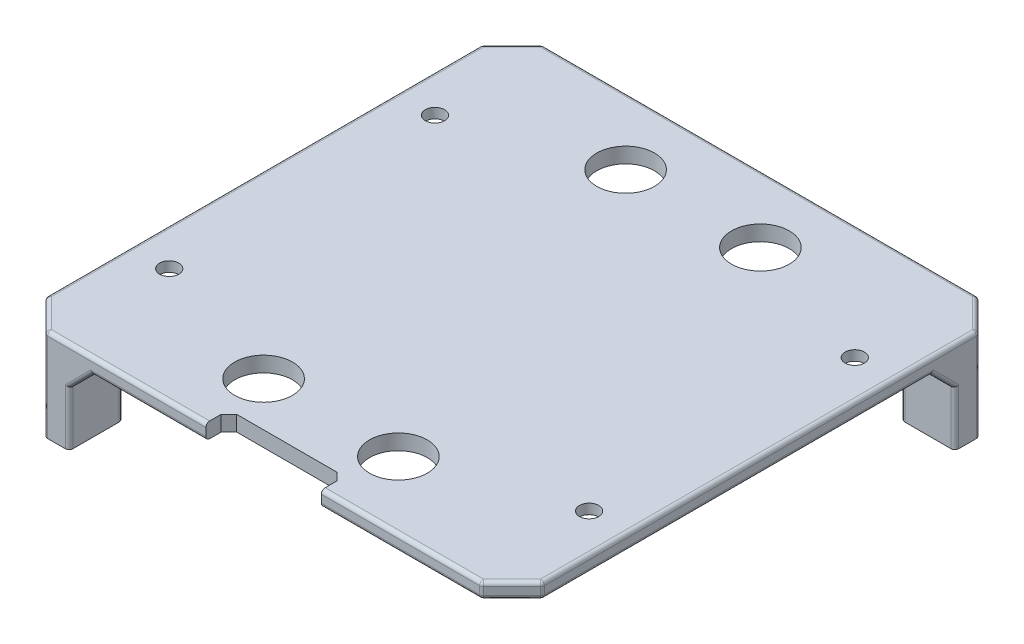
from build123d import *

# Parameters (mm, degrees)
SKETCH2_W                    = 64.5
SKETCH2_H                    = 64.5
BOSS_EXTRUDE1_DEPTH          = 2
SKETCH3_W                    = 7
SKETCH3_H                    = 7
BOSS_EXTRUDE2_DEPTH          = 10
SKETCH6_R                    = 1
CUT_EXTRUDE2_DEPTH           = 3
CHAMFER3_SIZE                = 3
CIRPATTERN1_COUNT            = 3
CIRPATTERN1_ANGLE            = 180
CHAMFER3_OF_CIRPATTERN1_SIZE = 3
CHAMFER8_SIZE                = 4
FILLET4_R                    = 0.5
SKETCH12_W                   = 15
SKETCH12_H                   = 3
CUT_EXTRUDE3_DEPTH           = 10
CHAMFER9_SIZE                = 1
SKETCH13_R                   = 3.75
CUT_EXTRUDE4_DEPTH           = 10
SKETCH16_R                   = 1.25
CUT_EXTRUDE6_DEPTH           = 10
CHAMFER10_SIZE               = 1
CHAMFER10_SIZE2              = 0.700207538


with BuildPart() as part:
    # Sketch2 → Boss-Extrude1 (new body)
    with BuildSketch(Plane(origin=(0, 0, 0), x_dir=(1, 0, 0), z_dir=(0, 1, 0))):
        Rectangle(SKETCH2_W, SKETCH2_H)
    extrude(amount=BOSS_EXTRUDE1_DEPTH)

    # Sketch3 → Boss-Extrude2 (add)
    with BuildSketch(Plane.XZ):
        with Locations((-28.75, 28.75)):
            Rectangle(SKETCH3_W, SKETCH3_H)
    boss_extrude2 = extrude(amount=BOSS_EXTRUDE2_DEPTH)

    # Sketch6 → Cut-Extrude2 (cut)
    with BuildSketch(Plane.XZ.offset(10)):
        with Locations((-28.75, 28.75)):
            Circle(SKETCH6_R)
    cut_extrude2 = extrude(amount=-CUT_EXTRUDE2_DEPTH, mode=Mode.SUBTRACT)

    # Chamfer3
    chamfer3_edges = [part.edges().sort_by_distance(p)[0] for p in [
        (-28.75, 0, 25.25),
        (-25.25, 0, 28.75),
    ]]
    chamfer(chamfer3_edges, length=CHAMFER3_SIZE)

    # CirPattern1: Boss-Extrude2, Cut-Extrude2 ×3 about axis
    cirpattern1_axis = Axis((0, 0, 0), (0, -1, 0))
    for i in range(1, CIRPATTERN1_COUNT):
        add(boss_extrude2.rotate(cirpattern1_axis, i * CIRPATTERN1_ANGLE / (CIRPATTERN1_COUNT - 1)))
        add(cut_extrude2.rotate(cirpattern1_axis, i * CIRPATTERN1_ANGLE / (CIRPATTERN1_COUNT - 1)), mode=Mode.SUBTRACT)

    # Chamfer3 of CirPattern1
    chamfer3_of_cirpattern1_edges = [part.edges().sort_by_distance(p)[0] for p in [
        (-25.25, 0, -28.75),
        (-28.75, 0, -25.25),
        (28.75, 0, -25.25),
        (25.25, 0, -28.75),
    ]]
    chamfer(chamfer3_of_cirpattern1_edges, length=CHAMFER3_OF_CIRPATTERN1_SIZE)

    # Chamfer8
    chamfer8_edges = [part.edges().sort_by_distance(p)[0] for p in [
        (32.25, 1, 32.25),
        (-32.25, -4, 32.25),
        (-32.25, -4, -32.25),
        (32.25, -4, -32.25),
    ]]
    chamfer(chamfer8_edges, length=CHAMFER8_SIZE)

    # Fillet4
    fillet4_edges = [part.edges().sort_by_distance(p)[0] for p in [
        (30.25, 0, 30.25),
        (0, 2, 32.25),
        (-28.25, -4, 32.25),
        (28.25, 1, 32.25),
        (0, 2, -32.25),
        (-32.25, 2, 0),
        (-30.25, 2, 30.25),
        (-30.25, 2, -30.25),
        (30.25, 2, -30.25),
        (30.25, 2, 30.25),
        (-28.25, -4, -32.25),
        (28.25, -4, -32.25),
        (-32.25, -4, 28.25),
        (-32.25, -4, -28.25),
        (-32.25, -6.5, 25.25),
        (-25.25, -6.5, 25.25),
        (-25.25, -6.5, 32.25),
        (3, 0, 32.25),
        (-23.75, -1.5, 32.25),
        (-32.25, -1.5, 23.75),
        (-25.25, -6.5, -32.25),
        (-25.25, -6.5, -25.25),
        (-32.25, -6.5, -25.25),
        (32.25, -6.5, -25.25),
        (25.25, -6.5, -25.25),
        (25.25, -6.5, -32.25),
        (-32.25, 0, 0),
        (-32.25, -1.5, -23.75),
        (-23.75, -1.5, -32.25),
        (0, 0, -32.25),
        (23.75, -1.5, -32.25),
        (32.25, -1.5, -23.75),
        (32.25, 0, 3),
        (32.25, 2, 0),
        (32.25, -4, -28.25),
        (32.25, 1, 28.25),
    ]]
    fillet(fillet4_edges, radius=FILLET4_R)

    # Sketch12 → Cut-Extrude3 (cut)
    with BuildSketch(Plane(origin=(0, 2, 0), x_dir=(1, 0, 0), z_dir=(0, 1, 0))):
        with Locations((0, -30.75)):
            Rectangle(SKETCH12_W, SKETCH12_H)
    extrude(amount=-CUT_EXTRUDE3_DEPTH, mode=Mode.SUBTRACT)

    # Chamfer9
    chamfer9_edges = [part.edges().sort_by_distance(p)[0] for p in [
        (-7.5, 1, 29.25),
        (7.5, 1, 29.25),
    ]]
    chamfer(chamfer9_edges, length=CHAMFER9_SIZE)

    # Sketch13 → Cut-Extrude4 (cut)
    with BuildSketch(Plane(origin=(0, 2, 0), x_dir=(1, 0, 0), z_dir=(0, 1, 0))):
        with Locations((8.75, -23.5)):
            Circle(SKETCH13_R)
        with Locations((-8.75, -23.5)):
            Circle(SKETCH13_R)
        with Locations((-8.75, 23.5)):
            Circle(SKETCH13_R)
        with Locations((8.75, 23.5)):
            Circle(SKETCH13_R)
    extrude(amount=-CUT_EXTRUDE4_DEPTH, mode=Mode.SUBTRACT)

    # Sketch16 → Cut-Extrude6 (cut)
    with BuildSketch(Plane.XZ):
        with Locations((-27.25, -17.25)):
            Circle(SKETCH16_R)
        with Locations((-27.25, 17.25)):
            Circle(SKETCH16_R)
        with Locations((27.25, -17.25)):
            Circle(SKETCH16_R)
        with Locations((27.25, 17.25)):
            Circle(SKETCH16_R)
    extrude(amount=-CUT_EXTRUDE6_DEPTH, mode=Mode.SUBTRACT)

    # Chamfer10
    chamfer10_edges = [part.edges().sort_by_distance(p)[0] for p in [
        (-28.5, 0, 17.25),
        (26, 0, -17.25),
        (26, 0, 17.25),
        (-28.5, 0, -17.25),
    ]]
    chamfer10_side = [part.faces().sort_by_distance(p)[0] for p in [
        (0.632372559, 0, 0.31600784),
    ]]
    chamfer(chamfer10_edges, length=CHAMFER10_SIZE, length2=CHAMFER10_SIZE2, reference=chamfer10_side[0])


solid = part.part
